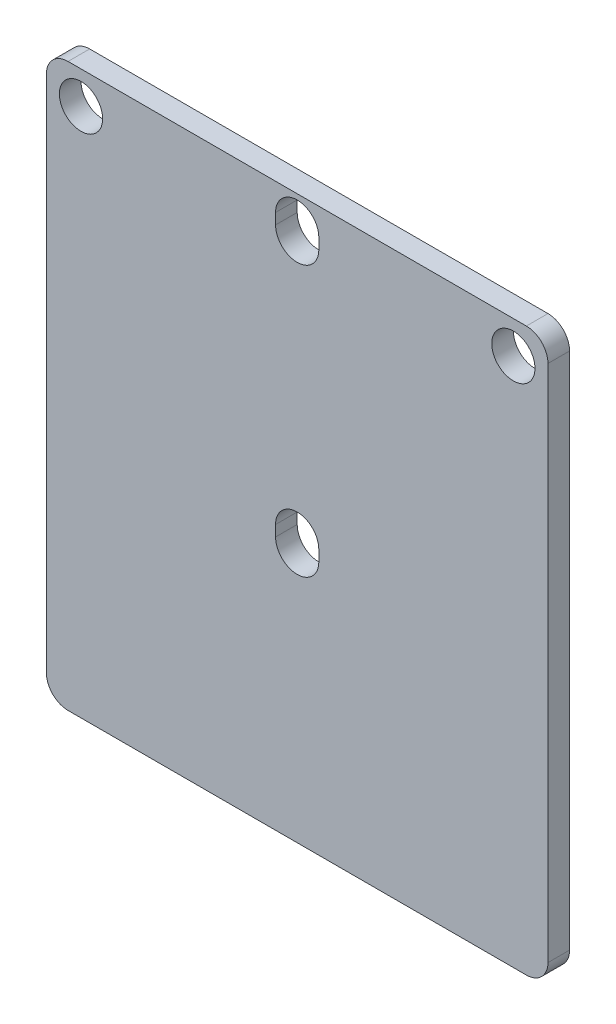
from build123d import *

# Parameters (mm, degrees)
ESQUISSE1_W             = 46.4
ESQUISSE1_H             = 52
EXTRUSION1_DEPTH        = 2
ESQUISSE2_R             = 2
ENL_V_MAT_EXTRU_1_DEPTH = 3
ENL_V_MAT_EXTRU_2_DEPTH = 3
CONG_1_R                = 2


with BuildPart() as part:
    # Esquisse1 → Extrusion1 (new body)
    with BuildSketch(Plane.XY):
        Rectangle(ESQUISSE1_W, ESQUISSE1_H)
    extrude(amount=EXTRUSION1_DEPTH)

    # Esquisse2 → Enlèv. mat.-Extru.1 (cut, through all)
    with BuildSketch(Plane.XY.offset(2)):
        with Locations((-20, 23)):
            Circle(ESQUISSE2_R)
        with Locations((20, 23)):
            Circle(ESQUISSE2_R)
    extrude(amount=-ENL_V_MAT_EXTRU_1_DEPTH, mode=Mode.SUBTRACT)

    # Esquisse3 → Enlèv. mat.-Extru.2 (cut, through all)
    with BuildSketch(Plane.XY.offset(2)):
        with BuildLine():
            Line((2, 23.5), (2, 22.5))
            ThreePointArc((2, 22.5), (0, 20.5), (-2, 22.5))
            Line((-2, 22.5), (-2, 23.5))
            ThreePointArc((-2, 23.5), (0, 25.5), (2, 23.5))
        make_face()
        with BuildLine():
            Line((2, -1.5), (2, -2.5))
            ThreePointArc((2, -2.5), (0, -4.5), (-2, -2.5))
            Line((-2, -2.5), (-2, -1.5))
            ThreePointArc((-2, -1.5), (0, 0.5), (2, -1.5))
        make_face()
    extrude(amount=-ENL_V_MAT_EXTRU_2_DEPTH, mode=Mode.SUBTRACT)

    # Congé1
    cong_1_edges = [part.edges().sort_by_distance(p)[0] for p in [
        (-23.2, 26, 1),
        (23.2, 26, 1),
        (23.2, -26, 1),
        (-23.2, -26, 1),
    ]]
    fillet(cong_1_edges, radius=CONG_1_R)


solid = part.part
